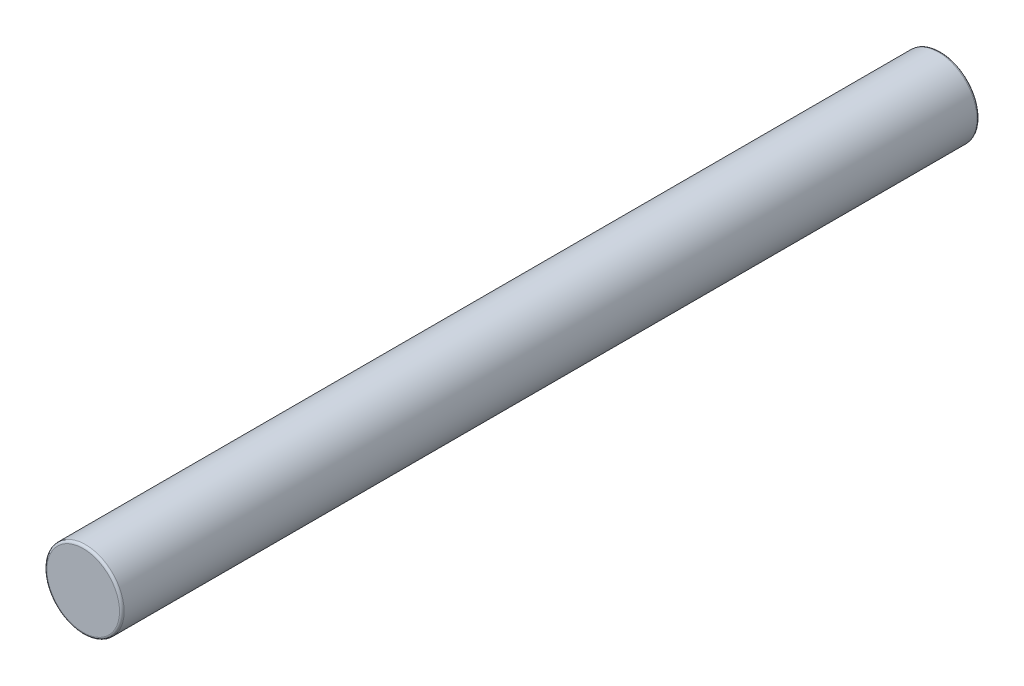
from build123d import *

# Parameters (mm, degrees)
SKETCH1_R           = 5
BOSS_EXTRUDE1_DEPTH = 55.5
FILLET1_R           = 0.3


with BuildPart() as part:
    # Sketch1 → Boss-Extrude1 (new body, symmetric)
    with BuildSketch(Plane.XY):
        Circle(SKETCH1_R)
    extrude(amount=BOSS_EXTRUDE1_DEPTH, both=True)

    # Fillet1
    fillet1_edges = [part.edges().sort_by_distance(p)[0] for p in [
        (-5, 0, -55.5),
        (-5, 0, 55.5),
    ]]
    fillet(fillet1_edges, radius=FILLET1_R)


solid = part.part
